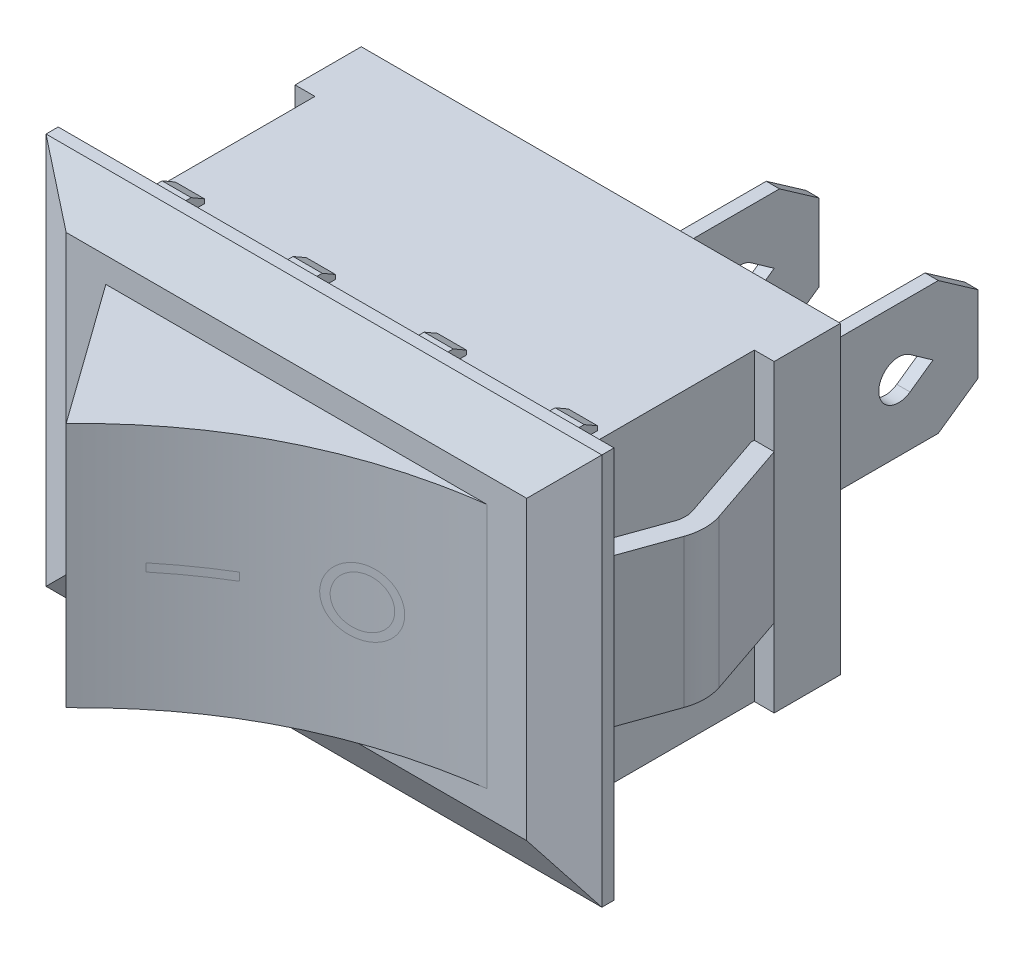
from build123d import *

# Parameters (mm, degrees)
SKETCH1_W                = 16.6
SKETCH1_H                = 11.5
BOSS_EXTRUDE1_DEPTH      = 10
SKETCH2_W                = 21
SKETCH2_H                = 14.8
BOSS_EXTRUDE2_DEPTH      = 1.5
SKETCH3_W                = 0.5
SKETCH3_H                = 5
BOSS_EXTRUDE3_DEPTH      = 8
SKETCH4_W                = 0.5
SKETCH4_H                = 0.4
CUT_EXTRUDE1_DEPTH       = 17.75
BOSS_EXTRUDE4_START      = -5.75
SKETCH5_W                = 0.75
SKETCH5_H                = 2.5
BOSS_EXTRUDE4_DEPTH      = 11.5
BOSS_EXTRUDE5_DEPTH      = 2.8
BOSS_EXTRUDE5_DEPTH_BACK = 2.8
CHAMFER1_SIZE            = 1.8
CHAMFER1_SIZE2           = 1.039230485
BOSS_EXTRUDE6_DEPTH      = 4.65
SKETCH9_W                = 1.1
SKETCH9_H                = 0.45
BOSS_EXTRUDE7_DEPTH      = 1.9
CHAMFER2_SIZE            = 0.5
CHAMFER2_SIZE2           = 0.288675135
CHAMFER2_PART_2_SIZE     = 0.5
CHAMFER2_PART_2_SIZE2    = 0.288675135
CHAMFER2_PART_3_SIZE     = 0.5
CHAMFER2_PART_3_SIZE2    = 0.288675135
CHAMFER2_PART_4_SIZE     = 0.5
CHAMFER2_PART_4_SIZE2    = 0.288675135
CHAMFER2_PART_5_SIZE     = 0.5
CHAMFER2_PART_5_SIZE2    = 0.288675135
CHAMFER2_PART_6_SIZE     = 0.5
CHAMFER2_PART_6_SIZE2    = 0.288675135
CHAMFER2_PART_7_SIZE     = 0.5
CHAMFER2_PART_7_SIZE2    = 0.288675135
CHAMFER2_PART_8_SIZE     = 0.5
CHAMFER2_PART_8_SIZE2    = 0.288675135


with BuildPart() as part:
    # Sketch1 → Boss-Extrude1 (new body)
    with BuildSketch(Plane.XY):
        Rectangle(SKETCH1_W, SKETCH1_H)
    extrude(amount=BOSS_EXTRUDE1_DEPTH)

    # Sketch2 → Boss-Extrude2 (add)
    with BuildSketch(Plane.XY.offset(10)):
        Rectangle(SKETCH2_W, SKETCH2_H)
    extrude(amount=BOSS_EXTRUDE2_DEPTH)

    # Sketch3 → Boss-Extrude3 (add)
    with BuildSketch(Plane(origin=(0, 0, 0), x_dir=(-1, 0, 0), z_dir=(0, 0, -1))):
        with Locations((-6, 0)):
            Rectangle(SKETCH3_W, SKETCH3_H)
        Rectangle(SKETCH3_W, SKETCH3_H)
    extrude(amount=BOSS_EXTRUDE3_DEPTH)

    # Sketch4 → Cut-Extrude1 (cut, through all)
    with BuildSketch(Plane(origin=(6.25, 0, 0), x_dir=(0, 0, -1), z_dir=(1, 0, 0))):
        with Locations((2.25, 2.3)):
            Rectangle(SKETCH4_W, SKETCH4_H)
        with BuildLine():
            Line((0, 0.75), (0, -0.75))
            ThreePointArc((0, -0.75), (0.75, 0), (0, 0.75))
        make_face()
        Polygon((6.5, 2.5), (8, 1.449688693), (8, 2.5), align=None)
        with BuildLine():
            Line((5.432692308, 0.612598863), (6.3, 0))
            Line((6.3, 0), (5.432692308, -0.612598863))
            ThreePointArc((5.432692308, -0.612598863), (4.25, 0), (5.432692308, 0.612598863))
        make_face()
        Polygon((8, -2.5), (8, -1.449688693), (6.5, -2.5), align=None)
        with Locations((2.25, -2.3)):
            Rectangle(SKETCH4_W, SKETCH4_H)
    extrude(amount=-CUT_EXTRUDE1_DEPTH, mode=Mode.SUBTRACT)

    # Sketch5 → Boss-Extrude4 (add)
    with BuildSketch(Plane(origin=(0, 0, 0), x_dir=(1, 0, 0), z_dir=(0, 1, 0)).offset(BOSS_EXTRUDE4_START)):
        with Locations((-8.675, -1.25)):
            Rectangle(SKETCH5_W, SKETCH5_H)
    boss_extrude4 = extrude(amount=BOSS_EXTRUDE4_DEPTH)

    # Mirror1: Boss-Extrude4 across plane
    add(boss_extrude4.mirror(Plane(origin=(0, 0, 0), x_dir=(0, 0, 1), z_dir=(1, 0, 0))))

    # Sketch6 → Boss-Extrude5 (add, two sides)
    with BuildSketch(Plane(origin=(0, 0, 0), x_dir=(1, 0, 0), z_dir=(0, 1, 0))) as boss_extrude5_sk:
        with BuildLine():
            Line((-9.05, -2.5), (-10.124907983, -5.653347952))
            ThreePointArc((-10.124907983, -5.653347952), (-10.231819447, -6.312838644), (-10.115557515, -6.970745323))
            Line((-10.115557515, -6.970745323), (-9.056614332, -9.938626949))
            Line((-9.056614332, -9.938626949), (-9.034716365, -10))
            Line((-9.034716365, -10), (-8.3, -10))
            Line((-8.3, -10), (-8.3, -9.827371619))
            Line((-8.3, -9.827371619), (-8.350231447, -9.686588817))
            Line((-8.350231447, -9.686588817), (-9.438479941, -6.636573707))
            ThreePointArc((-9.438479941, -6.636573707), (-9.496610907, -6.307620368), (-9.443155175, -5.977875022))
            Line((-9.443155175, -5.977875022), (-8.34011069, -2.741985882))
            Line((-8.34011069, -2.741985882), (-8.3, -2.624317241))
            Line((-8.3, -2.624317241), (-8.3, -2.5))
            Line((-8.3, -2.5), (-9.05, -2.5))
        make_face()
        with BuildLine():
            Line((8.3, -9.827371619), (8.350231447, -9.686588817))
            Line((8.350231447, -9.686588817), (9.438479941, -6.636573707))
            ThreePointArc((9.438479941, -6.636573707), (9.496610907, -6.307620368), (9.443155175, -5.977875022))
            Line((9.443155175, -5.977875022), (8.34011069, -2.741985882))
            Line((8.34011069, -2.741985882), (8.3, -2.624317241))
            Line((8.3, -2.624317241), (8.3, -2.5))
            Line((8.3, -2.5), (9.05, -2.5))
            Line((9.05, -2.5), (10.124907983, -5.653347952))
            ThreePointArc((10.124907983, -5.653347952), (10.231819447, -6.312838644), (10.115557515, -6.970745323))
            Line((10.115557515, -6.970745323), (9.056614332, -9.938626949))
            Line((9.056614332, -9.938626949), (9.034716365, -10))
            Line((9.034716365, -10), (8.3, -10))
            Line((8.3, -10), (8.3, -9.827371619))
        make_face()
    extrude(amount=BOSS_EXTRUDE5_DEPTH)
    extrude(boss_extrude5_sk.sketch, amount=-BOSS_EXTRUDE5_DEPTH_BACK)

    # Chamfer1
    chamfer1_edges = [part.edges().sort_by_distance(p)[0] for p in [
        (10.5, 0, 11.5),
        (0, 7.4, 11.5),
        (-10.5, 0, 11.5),
        (0, -7.4, 11.5),
    ]]
    chamfer1_side = [part.faces().sort_by_distance(p)[0] for p in [
        (0, 0, 11.5),
    ]]
    chamfer(chamfer1_edges, length=CHAMFER1_SIZE, length2=CHAMFER1_SIZE2, reference=chamfer1_side[0])

    # Sketch7 → Boss-Extrude6 (add, symmetric)
    with BuildSketch(Plane(origin=(0, 0, 0), x_dir=(1, 0, 0), z_dir=(0, 1, 0))):
        with BuildLine():
            Line((-7.2, -11.5), (-3.398718251, -16.8))
            add(Edge.make_bspline(
                [(-3.398718251, -16.8), (0.927387699, -12.334784825), (7.2, -11.5)],
                knots=[0, 0, 0, 1, 1, 1], degree=2))
            Line((7.2, -11.5), (-7.2, -11.5))
        make_face()
    extrude(amount=BOSS_EXTRUDE6_DEPTH, both=True)

    # Sketch9 → Boss-Extrude7 (add)
    with BuildSketch(Plane(origin=(0, 0, 10), x_dir=(-1, 0, 0), z_dir=(0, 0, -1))):
        with Locations((-7.425, 5.975)):
            Rectangle(SKETCH9_W, SKETCH9_H)
        with Locations((-2.475, 5.975)):
            Rectangle(SKETCH9_W, SKETCH9_H)
        with Locations((2.475, 5.975)):
            Rectangle(SKETCH9_W, SKETCH9_H)
        with Locations((7.425, 5.975)):
            Rectangle(SKETCH9_W, SKETCH9_H)
        with Locations((7.425, -5.975)):
            Rectangle(SKETCH9_W, SKETCH9_H)
        with Locations((2.475, -5.975)):
            Rectangle(SKETCH9_W, SKETCH9_H)
        with Locations((-2.475, -5.975)):
            Rectangle(SKETCH9_W, SKETCH9_H)
        with Locations((-7.425, -5.975)):
            Rectangle(SKETCH9_W, SKETCH9_H)
    extrude(amount=BOSS_EXTRUDE7_DEPTH)

    # Chamfer2
    chamfer2_edges = [part.edges().sort_by_distance(p)[0] for p in [
        (7.425, 6.2, 8.1),
    ]]
    chamfer2_side = [part.faces().sort_by_distance(p)[0] for p in [
        (7.425, 6.2, 9.05),
    ]]
    chamfer(chamfer2_edges, length=CHAMFER2_SIZE, length2=CHAMFER2_SIZE2, reference=chamfer2_side[0])

    # Chamfer2 part 2
    chamfer2_part_2_edges = [part.edges().sort_by_distance(p)[0] for p in [
        (2.475, 6.2, 8.1),
    ]]
    chamfer2_part_2_side = [part.faces().sort_by_distance(p)[0] for p in [
        (2.475, 6.2, 9.05),
    ]]
    chamfer(chamfer2_part_2_edges, length=CHAMFER2_PART_2_SIZE, length2=CHAMFER2_PART_2_SIZE2, reference=chamfer2_part_2_side[0])

    # Chamfer2 part 3
    chamfer2_part_3_edges = [part.edges().sort_by_distance(p)[0] for p in [
        (-2.475, 6.2, 8.1),
    ]]
    chamfer2_part_3_side = [part.faces().sort_by_distance(p)[0] for p in [
        (-2.475, 6.2, 9.05),
    ]]
    chamfer(chamfer2_part_3_edges, length=CHAMFER2_PART_3_SIZE, length2=CHAMFER2_PART_3_SIZE2, reference=chamfer2_part_3_side[0])

    # Chamfer2 part 4
    chamfer2_part_4_edges = [part.edges().sort_by_distance(p)[0] for p in [
        (-7.425, 6.2, 8.1),
    ]]
    chamfer2_part_4_side = [part.faces().sort_by_distance(p)[0] for p in [
        (-7.425, 6.2, 9.05),
    ]]
    chamfer(chamfer2_part_4_edges, length=CHAMFER2_PART_4_SIZE, length2=CHAMFER2_PART_4_SIZE2, reference=chamfer2_part_4_side[0])

    # Chamfer2 part 5
    chamfer2_part_5_edges = [part.edges().sort_by_distance(p)[0] for p in [
        (-7.425, -6.2, 8.1),
    ]]
    chamfer2_part_5_side = [part.faces().sort_by_distance(p)[0] for p in [
        (-7.425, -6.2, 9.05),
    ]]
    chamfer(chamfer2_part_5_edges, length=CHAMFER2_PART_5_SIZE, length2=CHAMFER2_PART_5_SIZE2, reference=chamfer2_part_5_side[0])

    # Chamfer2 part 6
    chamfer2_part_6_edges = [part.edges().sort_by_distance(p)[0] for p in [
        (-2.475, -6.2, 8.1),
    ]]
    chamfer2_part_6_side = [part.faces().sort_by_distance(p)[0] for p in [
        (-2.475, -6.2, 9.05),
    ]]
    chamfer(chamfer2_part_6_edges, length=CHAMFER2_PART_6_SIZE, length2=CHAMFER2_PART_6_SIZE2, reference=chamfer2_part_6_side[0])

    # Chamfer2 part 7
    chamfer2_part_7_edges = [part.edges().sort_by_distance(p)[0] for p in [
        (2.475, -6.2, 8.1),
    ]]
    chamfer2_part_7_side = [part.faces().sort_by_distance(p)[0] for p in [
        (2.475, -6.2, 9.05),
    ]]
    chamfer(chamfer2_part_7_edges, length=CHAMFER2_PART_7_SIZE, length2=CHAMFER2_PART_7_SIZE2, reference=chamfer2_part_7_side[0])

    # Chamfer2 part 8
    chamfer2_part_8_edges = [part.edges().sort_by_distance(p)[0] for p in [
        (7.425, -6.2, 8.1),
    ]]
    chamfer2_part_8_side = [part.faces().sort_by_distance(p)[0] for p in [
        (7.425, -6.2, 9.05),
    ]]
    chamfer(chamfer2_part_8_edges, length=CHAMFER2_PART_8_SIZE, length2=CHAMFER2_PART_8_SIZE2, reference=chamfer2_part_8_side[0])


solid = part.part
